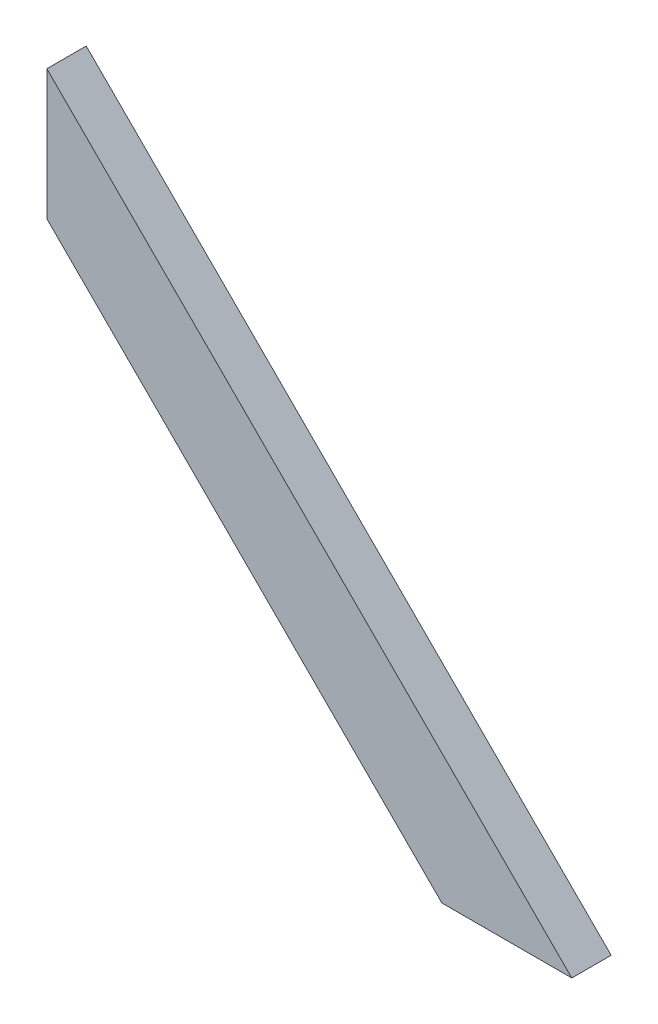
from build123d import *

# Parameters (mm, degrees)
BOSS_EXTRUDE1_DEPTH = 38.1


with BuildPart() as part:
    # Sketch1 → Boss-Extrude1 (new body)
    with BuildSketch(Plane.XY):
        Polygon((241.649804863, -34.884120172), (367.373390558, -34.884120172), (-140.626609442, 473.115879828), (-140.626609442, 347.392294133), align=None)
    extrude(amount=BOSS_EXTRUDE1_DEPTH)


solid = part.part
